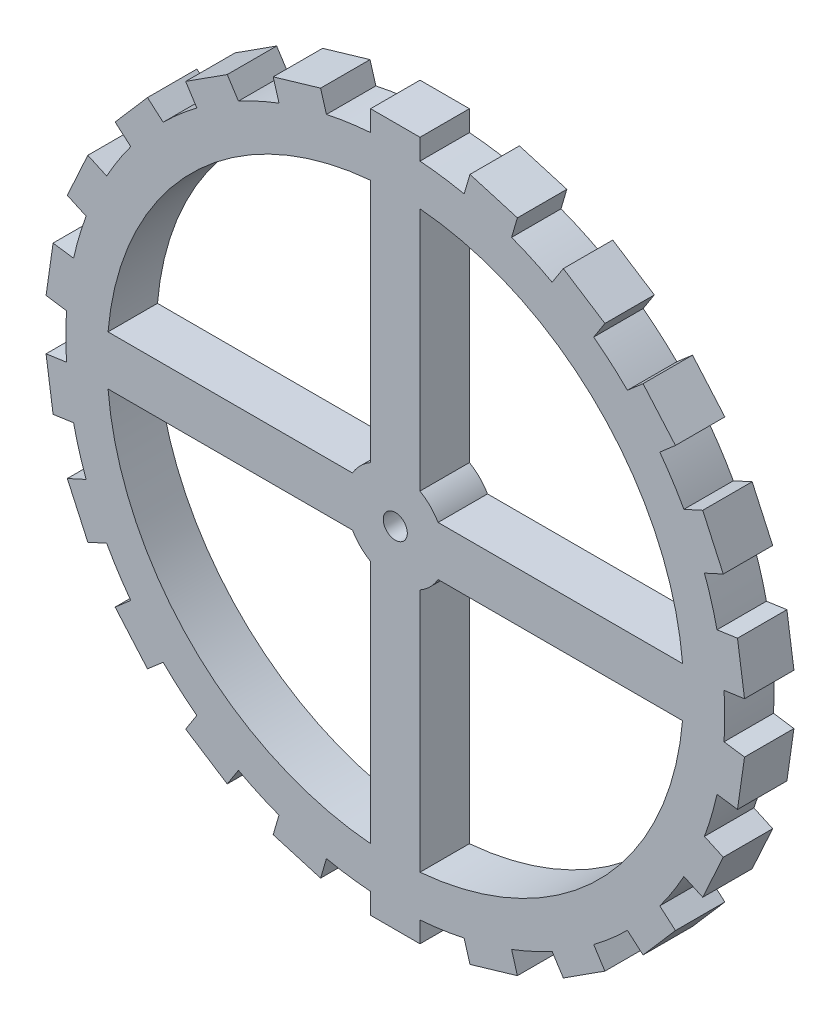
from build123d import *

# Parameters (mm, degrees)
SKETCH1_R           = 25.4
SKETCH1_R_2         = 0.9271
BOSS_EXTRUDE1_DEPTH = 3.81
BOSS_EXTRUDE2_DEPTH = 3.81


with BuildPart() as part:
    # Sketch1 → Boss-Extrude1 (new body)
    with BuildSketch(Plane.XY):
        Circle(SKETCH1_R)
        Circle(SKETCH1_R_2, mode=Mode.SUBTRACT)
        with BuildLine():
            Line((-1.905, 3.299556788), (-1.905, 22.143206633))
            ThreePointArc((-1.905, 22.143206633), (-15.715448212, 15.715448212), (-22.143206633, 1.905))
            Line((-22.143206633, 1.905), (-3.299556788, 1.905))
            ThreePointArc((-3.299556788, 1.905), (-2.694076836, 2.694076836), (-1.905, 3.299556788))
        make_face(mode=Mode.SUBTRACT)
        with BuildLine():
            Line((1.905, -22.143206633), (1.905, -3.299556788))
            ThreePointArc((1.905, -3.299556788), (2.694076836, -2.694076836), (3.299556788, -1.905))
            Line((3.299556788, -1.905), (22.143206633, -1.905))
            ThreePointArc((22.143206633, -1.905), (15.715448212, -15.715448212), (1.905, -22.143206633))
        make_face(mode=Mode.SUBTRACT)
        with BuildLine():
            Line((-1.905, -22.143206633), (-1.905, -3.299556788))
            ThreePointArc((-1.905, -3.299556788), (-2.694076836, -2.694076836), (-3.299556788, -1.905))
            Line((-3.299556788, -1.905), (-22.143206633, -1.905))
            ThreePointArc((-22.143206633, -1.905), (-15.715448212, -15.715448212), (-1.905, -22.143206633))
        make_face(mode=Mode.SUBTRACT)
        with BuildLine():
            Line((3.299556788, 1.905), (22.143206633, 1.905))
            ThreePointArc((22.143206633, 1.905), (15.715448212, 15.715448212), (1.905, 22.143206633))
            Line((1.905, 22.143206633), (1.905, 3.299556788))
            ThreePointArc((1.905, 3.299556788), (2.694076836, 2.694076836), (3.299556788, 1.905))
        make_face(mode=Mode.SUBTRACT)
    extrude(amount=BOSS_EXTRUDE1_DEPTH)

    # Sketch2 → Boss-Extrude2 (add)
    with BuildSketch(Plane.XY.offset(3.81)):
        with BuildLine():
            Line((5.308018177, 24.83918161), (5.757533246, 26.370089342))
            Line((5.757533246, 26.370089342), (9.413201475, 25.296688301))
            Line((9.413201475, 25.296688301), (8.963686407, 23.765780568))
            ThreePointArc((8.963686407, 23.765780568), (7.156006944, 24.37112153), (5.308018177, 24.83918161))
        make_face()
        with BuildLine():
            Line((-1.905, 25.328461757), (-1.905, 26.924))
            Line((-1.905, 26.924), (1.905, 26.924))
            Line((1.905, 26.924), (1.905, 25.328461757))
            ThreePointArc((1.905, 25.328461757), (0, 25.4), (-1.905, 25.328461757))
        make_face()
        with BuildLine():
            Line((12.091012289, 22.337578692), (12.953625389, 23.679830875))
            Line((12.953625389, 23.679830875), (16.158801349, 21.619989361))
            Line((16.158801349, 21.619989361), (15.296188249, 20.277737177))
            ThreePointArc((15.296188249, 20.277737177), (13.732276763, 21.367839734), (12.091012289, 22.337578692))
        make_face()
        with BuildLine():
            Line((17.894464494, 18.026317995), (19.100291842, 19.07117334))
            Line((19.100291842, 19.07117334), (21.595311238, 16.191767462))
            Line((21.595311238, 16.191767462), (20.38948389, 15.146912117))
            ThreePointArc((20.38948389, 15.146912117), (19.196039189, 16.633462642), (17.894464494, 18.026317995))
        make_face()
        with BuildLine():
            Line((22.248213608, 12.254672221), (23.699566243, 12.917482761))
            Line((23.699566243, 12.917482761), (25.282297443, 9.451784859))
            Line((25.282297443, 9.451784859), (23.830944807, 8.788974319))
            ThreePointArc((23.830944807, 8.788974319), (23.104652682, 10.55154133), (22.248213608, 12.254672221))
        make_face()
        with BuildLine():
            Line((24.79954477, 5.490225786), (26.378842734, 5.717294552))
            Line((26.378842734, 5.717294552), (26.921062268, 1.946074859))
            Line((26.921062268, 1.946074859), (25.341764304, 1.719006092))
            ThreePointArc((25.341764304, 1.719006092), (25.141464624, 3.614796892), (24.79954477, 5.490225786))
        make_face()
        with BuildLine():
            Line((25.341764304, -1.719006092), (26.921062268, -1.946074859))
            Line((26.921062268, -1.946074859), (26.378842734, -5.717294552))
            Line((26.378842734, -5.717294552), (24.79954477, -5.490225786))
            ThreePointArc((24.79954477, -5.490225786), (25.141464624, -3.614796892), (25.341764304, -1.719006092))
        make_face()
        with BuildLine():
            Line((23.830944807, -8.788974319), (25.282297443, -9.451784859))
            Line((25.282297443, -9.451784859), (23.699566243, -12.917482761))
            Line((23.699566243, -12.917482761), (22.248213608, -12.254672221))
            ThreePointArc((22.248213608, -12.254672221), (23.104652682, -10.55154133), (23.830944807, -8.788974319))
        make_face()
        with BuildLine():
            Line((20.38948389, -15.146912117), (21.595311238, -16.191767462))
            Line((21.595311238, -16.191767462), (19.100291842, -19.07117334))
            Line((19.100291842, -19.07117334), (17.894464494, -18.026317995))
            ThreePointArc((17.894464494, -18.026317995), (19.196039189, -16.633462642), (20.38948389, -15.146912117))
        make_face()
        with BuildLine():
            Line((15.296188249, -20.277737177), (16.158801349, -21.619989361))
            Line((16.158801349, -21.619989361), (12.953625389, -23.679830875))
            Line((12.953625389, -23.679830875), (12.091012289, -22.337578692))
            ThreePointArc((12.091012289, -22.337578692), (13.732276763, -21.367839734), (15.296188249, -20.277737177))
        make_face()
        with BuildLine():
            Line((8.963686407, -23.765780568), (9.413201475, -25.296688301))
            Line((9.413201475, -25.296688301), (5.757533246, -26.370089342))
            Line((5.757533246, -26.370089342), (5.308018177, -24.83918161))
            ThreePointArc((5.308018177, -24.83918161), (7.156006944, -24.37112153), (8.963686407, -23.765780568))
        make_face()
        with BuildLine():
            Line((1.905, -25.328461757), (1.905, -26.924))
            Line((1.905, -26.924), (-1.905, -26.924))
            Line((-1.905, -26.924), (-1.905, -25.328461757))
            ThreePointArc((-1.905, -25.328461757), (0, -25.4), (1.905, -25.328461757))
        make_face()
        with BuildLine():
            Line((-5.308018177, -24.83918161), (-5.757533246, -26.370089342))
            Line((-5.757533246, -26.370089342), (-9.413201475, -25.296688301))
            Line((-9.413201475, -25.296688301), (-8.963686407, -23.765780568))
            ThreePointArc((-8.963686407, -23.765780568), (-7.156006944, -24.37112153), (-5.308018177, -24.83918161))
        make_face()
        with BuildLine():
            Line((-12.091012289, -22.337578692), (-12.953625389, -23.679830875))
            Line((-12.953625389, -23.679830875), (-16.158801349, -21.619989361))
            Line((-16.158801349, -21.619989361), (-15.296188249, -20.277737177))
            ThreePointArc((-15.296188249, -20.277737177), (-13.732276763, -21.367839734), (-12.091012289, -22.337578692))
        make_face()
        with BuildLine():
            Line((-17.894464494, -18.026317995), (-19.100291842, -19.07117334))
            Line((-19.100291842, -19.07117334), (-21.595311238, -16.191767462))
            Line((-21.595311238, -16.191767462), (-20.38948389, -15.146912117))
            ThreePointArc((-20.38948389, -15.146912117), (-19.196039189, -16.633462642), (-17.894464494, -18.026317995))
        make_face()
        with BuildLine():
            Line((-22.248213608, -12.254672221), (-23.699566243, -12.917482761))
            Line((-23.699566243, -12.917482761), (-25.282297443, -9.451784859))
            Line((-25.282297443, -9.451784859), (-23.830944807, -8.788974319))
            ThreePointArc((-23.830944807, -8.788974319), (-23.104652682, -10.55154133), (-22.248213608, -12.254672221))
        make_face()
        with BuildLine():
            Line((-24.79954477, -5.490225786), (-26.378842734, -5.717294552))
            Line((-26.378842734, -5.717294552), (-26.921062268, -1.946074859))
            Line((-26.921062268, -1.946074859), (-25.341764304, -1.719006092))
            ThreePointArc((-25.341764304, -1.719006092), (-25.141464624, -3.614796892), (-24.79954477, -5.490225786))
        make_face()
        with BuildLine():
            Line((-25.341764304, 1.719006092), (-26.921062268, 1.946074859))
            Line((-26.921062268, 1.946074859), (-26.378842734, 5.717294552))
            Line((-26.378842734, 5.717294552), (-24.79954477, 5.490225786))
            ThreePointArc((-24.79954477, 5.490225786), (-25.141464624, 3.614796892), (-25.341764304, 1.719006092))
        make_face()
        with BuildLine():
            Line((-23.830944807, 8.788974319), (-25.282297443, 9.451784859))
            Line((-25.282297443, 9.451784859), (-23.699566243, 12.917482761))
            Line((-23.699566243, 12.917482761), (-22.248213608, 12.254672221))
            ThreePointArc((-22.248213608, 12.254672221), (-23.104652682, 10.55154133), (-23.830944807, 8.788974319))
        make_face()
        with BuildLine():
            Line((-20.38948389, 15.146912117), (-21.595311238, 16.191767462))
            Line((-21.595311238, 16.191767462), (-19.100291842, 19.07117334))
            Line((-19.100291842, 19.07117334), (-17.894464494, 18.026317995))
            ThreePointArc((-17.894464494, 18.026317995), (-19.196039189, 16.633462642), (-20.38948389, 15.146912117))
        make_face()
        with BuildLine():
            Line((-15.296188249, 20.277737177), (-16.158801349, 21.619989361))
            Line((-16.158801349, 21.619989361), (-12.953625389, 23.679830875))
            Line((-12.953625389, 23.679830875), (-12.091012289, 22.337578692))
            ThreePointArc((-12.091012289, 22.337578692), (-13.732276763, 21.367839734), (-15.296188249, 20.277737177))
        make_face()
        with BuildLine():
            Line((-8.963686407, 23.765780568), (-9.413201475, 25.296688301))
            Line((-9.413201475, 25.296688301), (-5.757533246, 26.370089342))
            Line((-5.757533246, 26.370089342), (-5.308018177, 24.83918161))
            ThreePointArc((-5.308018177, 24.83918161), (-7.156006944, 24.37112153), (-8.963686407, 23.765780568))
        make_face()
    extrude(amount=-BOSS_EXTRUDE2_DEPTH)


solid = part.part
